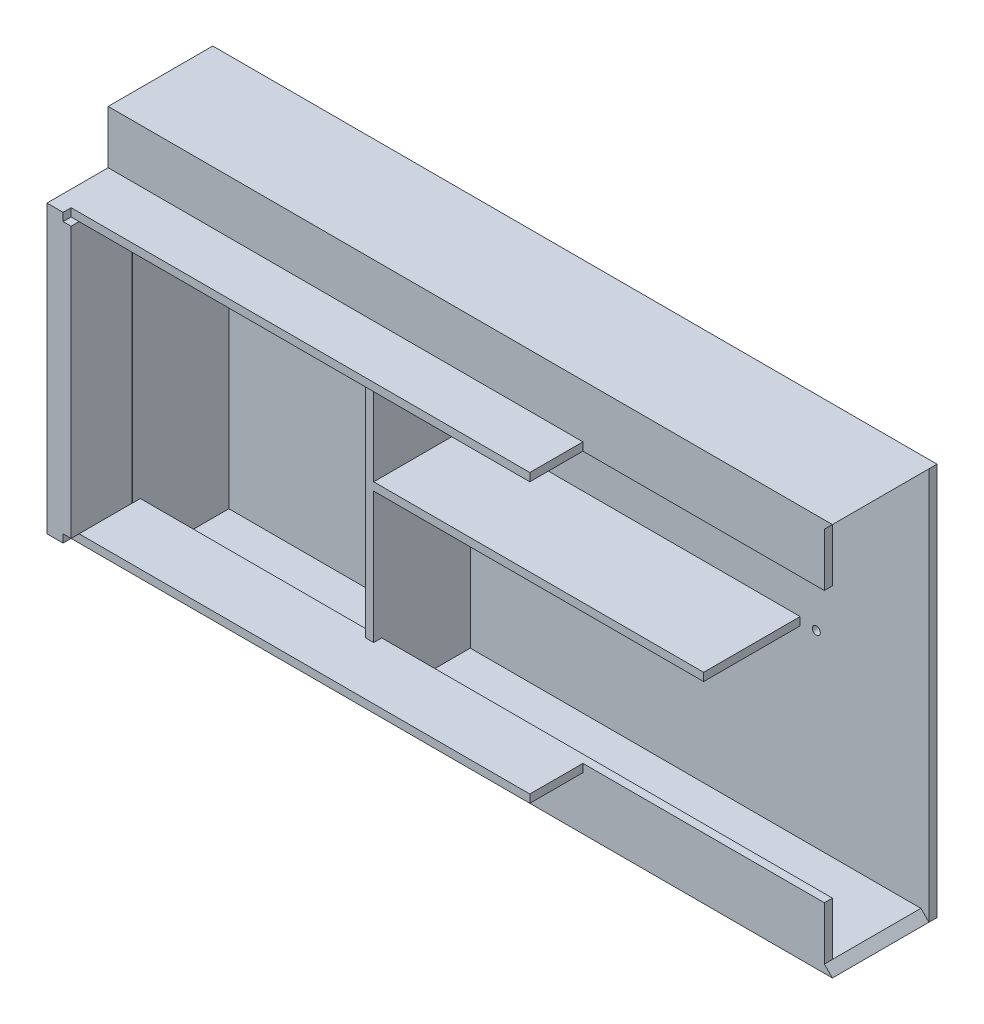
from build123d import *

# Parameters (mm, degrees)
SKETCH1_W           = 440
SKETCH1_H           = 244
SKETCH1_W_2         = 60
SKETCH1_H_2         = 204
BOSS_EXTRUDE1_DEPTH = 5
BOSS_EXTRUDE2_DEPTH = 60
SKETCH3_W           = 65
SKETCH3_H           = 244
BOSS_EXTRUDE3_DEPTH = 10
SKETCH9_W           = 430
SKETCH9_H           = 5
BOSS_EXTRUDE6_DEPTH = 33
BOSS_EXTRUDE7_DEPTH = 38
SKETCH11_W          = 38
SKETCH11_H          = 33
CUT_EXTRUDE3_DEPTH  = 38
SKETCH12_W          = 13
SKETCH12_H          = 50
CUT_EXTRUDE4_DEPTH  = 10
CUT_EXTRUDE4_TAPER  = 30
CUT_EXTRUDE6_DEPTH  = 30
SKETCH16_W          = 5
SKETCH16_H          = 5
CUT_EXTRUDE7_DEPTH  = 435
SKETCH17_W          = 5
SKETCH17_H          = 234
BOSS_EXTRUDE8_DEPTH = 60
SKETCH18_W          = 210
SKETCH18_H          = 5
BOSS_EXTRUDE9_DEPTH = 60
SKETCH19_R          = 2.5
CUT_EXTRUDE8_DEPTH  = 50
SKETCH22_W          = 33
SKETCH22_H          = 5
CUT_EXTRUDE10_DEPTH = 150


with BuildPart() as part:
    # Sketch1 → Boss-Extrude1 (new body)
    with BuildSketch(Plane.XY):
        Rectangle(SKETCH1_W, SKETCH1_H)
        with Locations((-100, 0)):
            Rectangle(SKETCH1_W_2, SKETCH1_H_2, mode=Mode.SUBTRACT)
    extrude(amount=BOSS_EXTRUDE1_DEPTH)

    # Sketch2 → Boss-Extrude2 (add)
    with BuildSketch(Plane.XY.offset(5)):
        Polygon((-215, -117), (215, -117), (220, -122), (-220, -122), (-220, 122), (220, 122), (215, 117), (-215, 117), align=None)
    extrude(amount=BOSS_EXTRUDE2_DEPTH)

    # Sketch3 → Boss-Extrude3 (add)
    with BuildSketch(Plane.ZY.offset(220)):
        with Locations((32.5, 0)):
            Rectangle(SKETCH3_W, SKETCH3_H)
    extrude(amount=BOSS_EXTRUDE3_DEPTH)

    # Sketch9 → Boss-Extrude6 (add)
    with BuildSketch(Plane(origin=(0, -117, 0), x_dir=(1, 0, 0), z_dir=(0, 1, 0))):
        with Locations((0, -62.5)):
            Rectangle(SKETCH9_W, SKETCH9_H)
    boss_extrude6 = extrude(amount=BOSS_EXTRUDE6_DEPTH)

    # Sketch10 → Boss-Extrude7 (add)
    with BuildSketch(Plane.XY.offset(65)):
        Polygon((215, -84), (-215.042545238, -84), (-215.042545238, 122), (-230, 122), (-230, -89), (-215.042545238, -89), (215, -89), align=None)
    boss_extrude7 = extrude(amount=BOSS_EXTRUDE7_DEPTH)

    # Mirror4: Boss-Extrude6, Boss-Extrude7 across plane
    add(boss_extrude6.mirror(Plane.ZX))
    add(boss_extrude7.mirror(Plane.ZX))

    # Sketch11 → Cut-Extrude3 (cut)
    with BuildSketch(Plane(origin=(-215.042545238, 0, 0), x_dir=(0, 0, -1), z_dir=(1, 0, 0))):
        with Locations((-84, 105.5)):
            Rectangle(SKETCH11_W, SKETCH11_H)
        with Locations((-84, -105.5)):
            Rectangle(SKETCH11_W, SKETCH11_H)
    extrude(amount=-CUT_EXTRUDE3_DEPTH, mode=Mode.SUBTRACT)

    # Sketch12 → Cut-Extrude4 (cut)
    with BuildSketch(Plane.ZY.offset(230)):
        with Locations((38, 0)):
            Rectangle(SKETCH12_W, SKETCH12_H)
        with Locations((65, 0)):
            Rectangle(SKETCH12_W, SKETCH12_H)
    extrude(amount=-CUT_EXTRUDE4_DEPTH, taper=CUT_EXTRUDE4_TAPER, mode=Mode.SUBTRACT)

    # Sketch14 → Cut-Extrude6 (cut, symmetric)
    with BuildSketch(Plane(origin=(0, 0, 0), x_dir=(1, 0, 0), z_dir=(0, 1, 0))):
        Polygon((-230, -71.5), (-219.022191852, -54.5), (-230, -58.5), align=None)
        Polygon((-230, -31.5), (-219.022191852, -48.5), (-230, -44.5), align=None)
    extrude(amount=CUT_EXTRUDE6_DEPTH, both=True, mode=Mode.SUBTRACT)

    # Sketch16 → Cut-Extrude7 (cut)
    with BuildSketch(Plane(origin=(215, 0, 0), x_dir=(0, 0, -1), z_dir=(1, 0, 0))):
        with Locations((-100.5, -86.5)):
            Rectangle(SKETCH16_W, SKETCH16_H)
        with Locations((-100.5, 86.5)):
            Rectangle(SKETCH16_W, SKETCH16_H)
    extrude(amount=-CUT_EXTRUDE7_DEPTH, mode=Mode.SUBTRACT)

    # Sketch17 → Boss-Extrude8 (add)
    with BuildSketch(Plane.XY.offset(5)):
        with Locations((-67.5, 0)):
            Rectangle(SKETCH17_W, SKETCH17_H)
    extrude(amount=BOSS_EXTRUDE8_DEPTH)

    # Sketch18 → Boss-Extrude9 (add)
    with BuildSketch(Plane.XY.offset(5)):
        with Locations((35, 0)):
            Rectangle(SKETCH18_W, SKETCH18_H)
    extrude(amount=BOSS_EXTRUDE9_DEPTH)

    # Sketch19 → Cut-Extrude8 (cut)
    with BuildSketch(Plane.XY.offset(5)):
        with Locations((150, 0)):
            Circle(SKETCH19_R)
    extrude(amount=-CUT_EXTRUDE8_DEPTH, mode=Mode.SUBTRACT)

    # Sketch22 → Cut-Extrude10 (cut)
    with BuildSketch(Plane(origin=(215, 0, 0), x_dir=(0, 0, -1), z_dir=(1, 0, 0))):
        with Locations((-81.5, -86.5)):
            Rectangle(SKETCH22_W, SKETCH22_H)
        with Locations((-81.5, 86.5)):
            Rectangle(SKETCH22_W, SKETCH22_H)
    extrude(amount=-CUT_EXTRUDE10_DEPTH, mode=Mode.SUBTRACT)


solid = part.part
